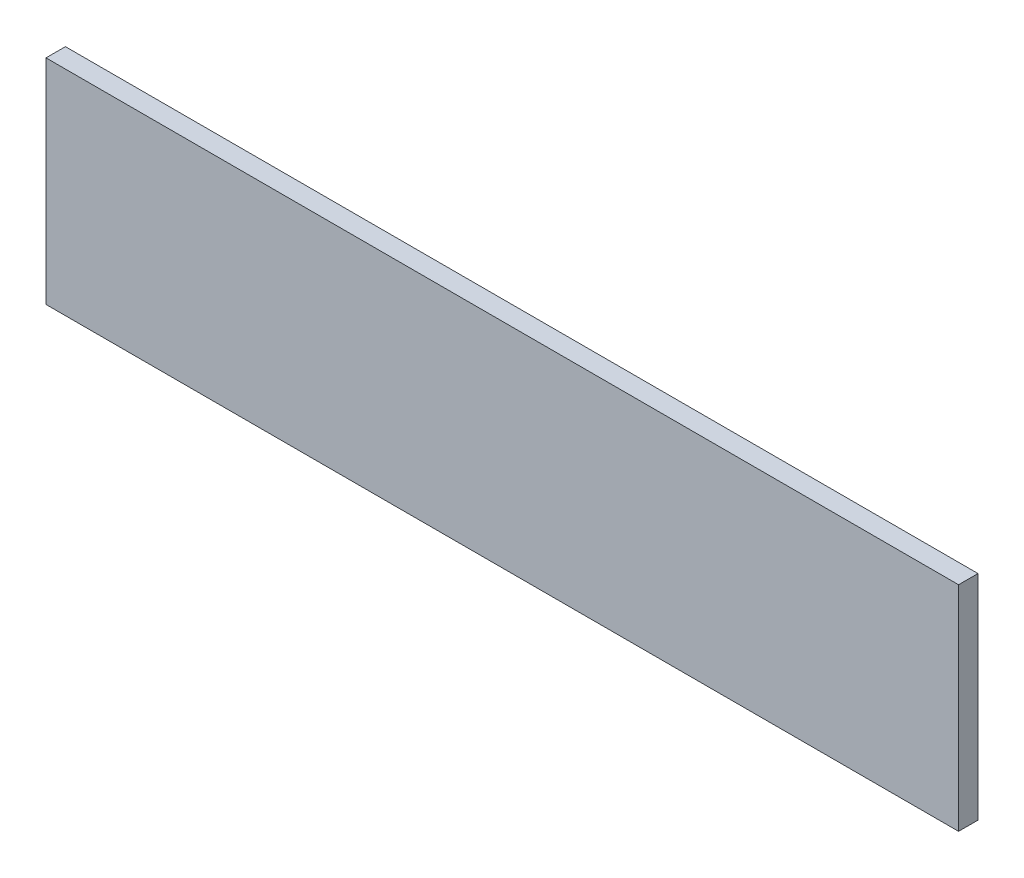
from build123d import *

# Parameters (mm, degrees)
ESQUISSE1_W        = 470
ESQUISSE1_H        = 110
BOSS_EXTRU_1_DEPTH = 10


with BuildPart() as part:
    # Esquisse1 → Boss.-Extru.1 (new body)
    with BuildSketch(Plane.XY):
        with Locations((235, 55)):
            Rectangle(ESQUISSE1_W, ESQUISSE1_H)
    extrude(amount=BOSS_EXTRU_1_DEPTH)


solid = part.part
